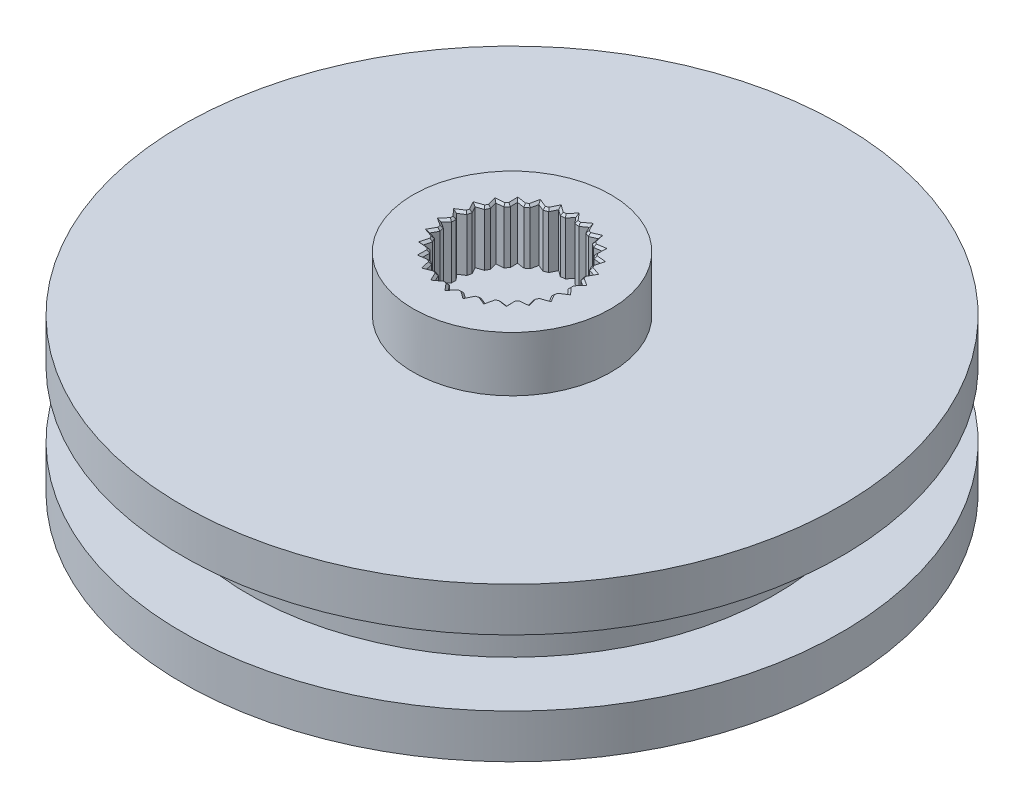
from build123d import *

# Parameters (mm, degrees)
SKETCH1_R           = 10
SKETCH1_R_2         = 1.25
SKETCH1_R_3         = 1.5
BOSS_EXTRUDE1_DEPTH = 2
SKETCH2_R           = 4.5
SKETCH2_R_2         = 1.5
BOSS_EXTRUDE2_DEPTH = 2.5
SKETCH3_R           = 2.25
CUT_EXTRUDE1_DEPTH  = 3.6
CUT_EXTRUDE2_DEPTH  = 3.6
CHAMFER1_SIZE       = 0.1
SKETCH8_R           = 10
CUT_EXTRUDE3_DEPTH  = 2
SKETCH9_R           = 15
BOSS_EXTRUDE3_DEPTH = 2
SKETCH10_R          = 12
BOSS_EXTRUDE4_DEPTH = 3
SKETCH11_R          = 15
BOSS_EXTRUDE5_DEPTH = 2


with BuildPart() as part:
    # Sketch1 → Boss-Extrude1 (new body)
    with BuildSketch(Plane(origin=(0, 0, 0), x_dir=(1, 0, 0), z_dir=(0, 1, 0))):
        Circle(SKETCH1_R)
        with Locations((-4.949747468, 4.949747468)):
            Circle(SKETCH1_R_2, mode=Mode.SUBTRACT)
        with Locations((4.949747468, 4.949747468)):
            Circle(SKETCH1_R_2, mode=Mode.SUBTRACT)
        with Locations((4.949747468, -4.949747468)):
            Circle(SKETCH1_R_2, mode=Mode.SUBTRACT)
        with Locations((-4.949747468, -4.949747468)):
            Circle(SKETCH1_R_2, mode=Mode.SUBTRACT)
        Circle(SKETCH1_R_3, mode=Mode.SUBTRACT)
    extrude(amount=BOSS_EXTRUDE1_DEPTH)

    # Sketch2 → Boss-Extrude2 (add)
    with BuildSketch(Plane(origin=(0, 2, 0), x_dir=(1, 0, 0), z_dir=(0, 1, 0))):
        Circle(SKETCH2_R)
        Circle(SKETCH2_R_2, mode=Mode.SUBTRACT)
    extrude(amount=BOSS_EXTRUDE2_DEPTH)

    # Sketch3 → Cut-Extrude1 (cut)
    with BuildSketch(Plane(origin=(0, 4.5, 0), x_dir=(1, 0, 0), z_dir=(0, 1, 0))):
        Circle(SKETCH3_R)
    extrude(amount=-CUT_EXTRUDE1_DEPTH, mode=Mode.SUBTRACT)

    # Sketch7 → Cut-Extrude2 (cut)
    with BuildSketch(Plane(origin=(0, 4.5, 0), x_dir=(1, 0, 0), z_dir=(0, 1, 0))):
        Polygon((-0.842998944, 2.512340101), (-1.034995876, 2.439525269), (-1.129082655, 2.478127827), (-1.347697199, 2.567822474), (-1.398067166, 2.336953865), (-1.419745267, 2.237593211), (-1.588737387, 2.120946373), (-1.689328372, 2.13591077), (-1.923055709, 2.17068117), (-1.916711542, 1.93446686), (-1.913981155, 1.832805537), (-2.050147256, 1.679105783), (-2.151396465, 1.669562343), (-2.386653211, 1.647387766), (-2.32396361, 1.419555673), (-2.296983416, 1.321501868), (-2.392410018, 1.139681668), (-2.488433215, 1.106185022), (-2.711547104, 1.028354172), (-2.59615536, 0.82214507), (-2.54649335, 0.733397313), (-2.595634607, 0.534023397), (-2.680851271, 0.478520248), (-2.878855735, 0.349556373), (-2.717467997, 0.176954384), (-2.648010346, 0.102670372), (-2.648010346, -0.102670372), (-2.717467997, -0.176954384), (-2.878855735, -0.349556373), (-2.680851271, -0.478520248), (-2.595634607, -0.534023397), (-2.54649335, -0.733397313), (-2.59615536, -0.82214507), (-2.711547104, -1.028354172), (-2.488433215, -1.106185022), (-2.392410018, -1.139681668), (-2.296983416, -1.321501868), (-2.32396361, -1.419555673), (-2.386653211, -1.647387766), (-2.151396465, -1.669562343), (-2.050147256, -1.679105783), (-1.913981155, -1.832805537), (-1.916711542, -1.93446686), (-1.923055709, -2.17068117), (-1.689328372, -2.13591077), (-1.588737387, -2.120946373), (-1.419745267, -2.237593211), (-1.398067166, -2.336953865), (-1.347697199, -2.567822474), (-1.129082655, -2.478127827), (-1.034995876, -2.439525269), (-0.842998944, -2.512340101), (-0.798172209, -2.603625605), (-0.694015426, -2.815731271), (-0.503218758, -2.676325101), (-0.421104166, -2.616327824), (-0.217260587, -2.641078915), (-0.151890384, -2.718984089), (0, -2.9), (0.151890384, -2.718984089), (0.217260587, -2.641078915), (0.421104166, -2.616327824), (0.503218758, -2.676325101), (0.694015426, -2.815731271), (0.798172209, -2.603625605), (0.842998944, -2.512340101), (1.034995876, -2.439525269), (1.129082655, -2.478127827), (1.347697199, -2.567822474), (1.398067166, -2.336953865), (1.419745267, -2.237593211), (1.588737387, -2.120946373), (1.689328372, -2.13591077), (1.923055709, -2.17068117), (1.916711542, -1.93446686), (1.913981155, -1.832805537), (2.050147256, -1.679105783), (2.151396465, -1.669562343), (2.386653211, -1.647387766), (2.32396361, -1.419555673), (2.296983416, -1.321501868), (2.392410018, -1.139681668), (2.488433215, -1.106185022), (2.711547104, -1.028354172), (2.59615536, -0.82214507), (2.54649335, -0.733397313), (2.595634607, -0.534023397), (2.680851271, -0.478520248), (2.878855735, -0.349556373), (2.717467997, -0.176954384), (2.648010346, -0.102670372), (2.648010346, 0.102670372), (2.717467997, 0.176954384), (2.878855735, 0.349556373), (2.680851271, 0.478520248), (2.595634607, 0.534023397), (2.54649335, 0.733397313), (2.59615536, 0.82214507), (2.711547104, 1.028354172), (2.488433215, 1.106185022), (2.392410018, 1.139681668), (2.296983416, 1.321501868), (2.32396361, 1.419555673), (2.386653211, 1.647387766), (2.151396465, 1.669562343), (2.050147256, 1.679105783), (1.913981155, 1.832805537), (1.916711542, 1.93446686), (1.923055709, 2.17068117), (1.689328372, 2.13591077), (1.588737387, 2.120946373), (1.419745267, 2.237593211), (1.398067166, 2.336953865), (1.347697199, 2.567822474), (1.129082655, 2.478127827), (1.034995876, 2.439525269), (0.842998944, 2.512340101), (0.798172209, 2.603625605), (0.694015426, 2.815731271), (0.503218758, 2.676325101), (0.421104166, 2.616327824), (0.217260587, 2.641078915), (0.151890384, 2.718984089), (0, 2.9), (-0.151890384, 2.718984089), (-0.217260587, 2.641078915), (-0.421104166, 2.616327824), (-0.503218758, 2.676325101), (-0.694015426, 2.815731271), (-0.798172209, 2.603625605), align=None)
    extrude(amount=-CUT_EXTRUDE2_DEPTH, mode=Mode.SUBTRACT)

    # Chamfer1
    chamfer1_edges = [part.edges().sort_by_distance(p)[0] for p in [
        (-2.218400233, 4.5, 1.663246774),
        (-1.982064206, 4.5, 1.75595566),
        (-1.918518432, 4.5, 2.001743353),
        (-1.755896548, 4.5, 2.145813771),
        (-1.504241327, 4.5, 2.179269792),
        (-1.383721233, 4.5, 2.402707843),
        (-1.191346537, 4.5, 2.503673872),
        (-0.93899741, 4.5, 2.475932685),
        (-0.768507185, 4.5, 2.664035686),
        (-0.557559796, 4.5, 2.716029547),
        (-0.319182376, 4.5, 2.62870337),
        (-0.108630293, 4.5, 2.770539458),
        (0.108630293, 4.5, 2.770539458),
        (0.319182376, 4.5, 2.62870337),
        (0.557559796, 4.5, 2.716029547),
        (0.768507185, 4.5, 2.664035686),
        (0.93899741, 4.5, 2.475932685),
        (1.191346537, 4.5, 2.503673872),
        (1.383721233, 4.5, 2.402707843),
        (1.504241327, 4.5, 2.179269792),
        (1.755896548, 4.5, 2.145813771),
        (1.918518432, 4.5, 2.001743353),
        (1.982064206, 4.5, 1.75595566),
        (2.218400233, 4.5, 1.663246774),
        (2.341818314, 4.5, 1.484444817),
        (2.344696717, 4.5, 1.230591768),
        (2.551978561, 4.5, 1.08401792),
        (2.629020227, 4.5, 0.880875743),
        (2.571063978, 4.5, 0.633710355),
        (2.737245171, 4.5, 0.441789885),
        (2.763433041, 4.5, 0.226113373),
        (2.648010346, 4.5, 0),
        (2.763433041, 4.5, -0.226113373),
        (2.737245171, 4.5, -0.441789885),
        (2.571063978, 4.5, -0.633710355),
        (2.629020227, 4.5, -0.880875743),
        (2.551978561, 4.5, -1.08401792),
        (2.344696717, 4.5, -1.230591768),
        (2.341818314, 4.5, -1.484444817),
        (2.218400233, 4.5, -1.663246774),
        (1.982064206, 4.5, -1.75595566),
        (1.918518432, 4.5, -2.001743353),
        (1.755896548, 4.5, -2.145813771),
        (1.504241327, 4.5, -2.179269792),
        (1.383721233, 4.5, -2.402707843),
        (1.191346537, 4.5, -2.503673872),
        (0.93899741, 4.5, -2.475932685),
        (0.768507185, 4.5, -2.664035686),
        (0.557559796, 4.5, -2.716029547),
        (0.319182376, 4.5, -2.62870337),
        (0.108630293, 4.5, -2.770539458),
        (-0.108630293, 4.5, -2.770539458),
        (-0.319182376, 4.5, -2.62870337),
        (-0.557559796, 4.5, -2.716029547),
        (-0.768507185, 4.5, -2.664035686),
        (-0.93899741, 4.5, -2.475932685),
        (-1.191346537, 4.5, -2.503673872),
        (-1.383721233, 4.5, -2.402707843),
        (-1.504241327, 4.5, -2.179269792),
        (-1.755896548, 4.5, -2.145813771),
        (-1.918518432, 4.5, -2.001743353),
        (-1.982064206, 4.5, -1.75595566),
        (-2.218400233, 4.5, -1.663246774),
        (-2.341818314, 4.5, -1.484444817),
        (-2.344696717, 4.5, -1.230591768),
        (-2.551978561, 4.5, -1.08401792),
        (-2.629020227, 4.5, -0.880875743),
        (-2.571063978, 4.5, -0.633710355),
        (-2.737245171, 4.5, -0.441789885),
        (-2.763433041, 4.5, -0.226113373),
        (-2.648010346, 4.5, 0),
        (-2.763433041, 4.5, 0.226113373),
        (-2.737245171, 4.5, 0.441789885),
        (-2.571063978, 4.5, 0.633710355),
        (-2.629020227, 4.5, 0.880875743),
        (-2.551978561, 4.5, 1.08401792),
        (-2.344696717, 4.5, 1.230591768),
        (-2.341818314, 4.5, 1.484444817),
    ]]
    chamfer(chamfer1_edges, length=CHAMFER1_SIZE)

    # Sketch8 → Cut-Extrude3 (cut)
    with BuildSketch(Plane.XZ):
        Circle(SKETCH8_R)
    extrude(amount=-CUT_EXTRUDE3_DEPTH, mode=Mode.SUBTRACT)

    # Sketch9 → Boss-Extrude3 (add)
    with BuildSketch(Plane.XZ.offset(-2)):
        Circle(SKETCH9_R)
    extrude(amount=BOSS_EXTRUDE3_DEPTH)

    # Sketch10 → Boss-Extrude4 (add)
    with BuildSketch(Plane.XZ):
        Circle(SKETCH10_R)
    extrude(amount=BOSS_EXTRUDE4_DEPTH)

    # Sketch11 → Boss-Extrude5 (add)
    with BuildSketch(Plane.XZ.offset(3)):
        Circle(SKETCH11_R)
    extrude(amount=BOSS_EXTRUDE5_DEPTH)


solid = part.part
